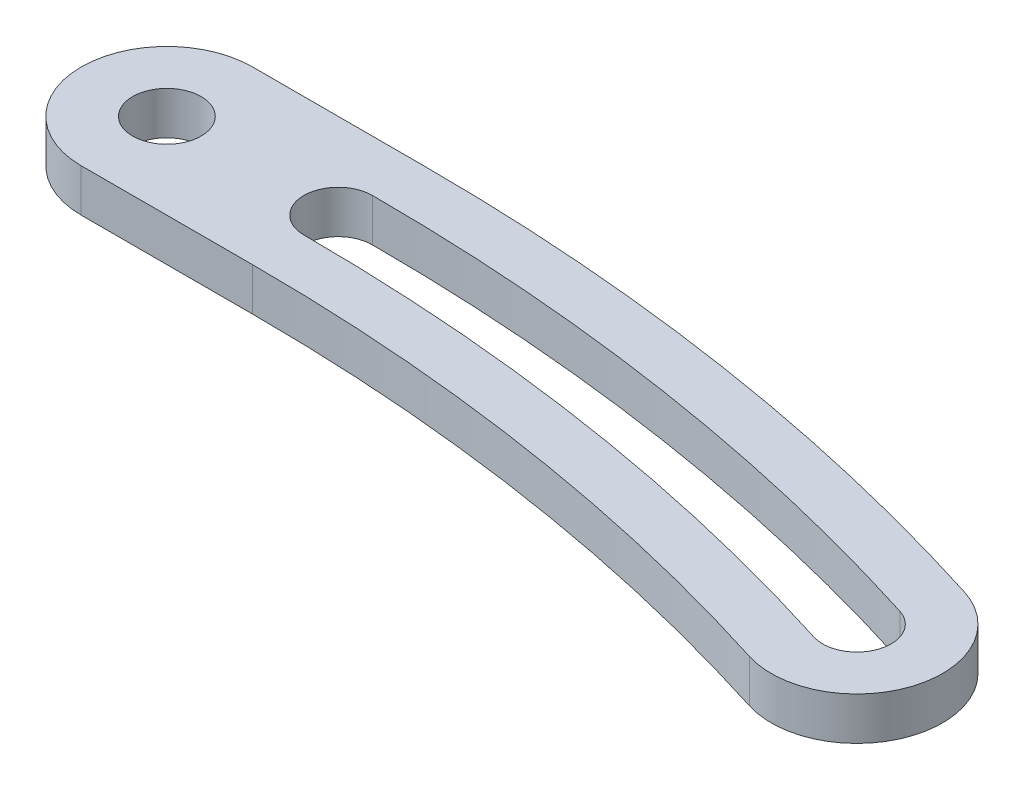
from build123d import *

# Parameters (mm, degrees)
SKETCH_2_R      = 1.6
EXTRUDE_1_DEPTH = 2


with BuildPart() as part:
    # 草图2 → 凸台-拉伸1 (new body)
    with BuildSketch(Plane(origin=(0, 0, 0), x_dir=(1, 0, 0), z_dir=(0, 1, 0))):
        with BuildLine():
            Line((-8, 4), (0, 4))
            ThreePointArc((0, 4), (15.110526316, 2.840032678), (29.866957344, -0.612686981))
            ThreePointArc((29.866957344, -0.612686981), (32.473840401, -5.633061541), (27.453465841, -8.239944598))
            ThreePointArc((27.453465841, -8.239944598), (13.889473684, -5.066232589), (0, -4))
            Line((0, -4), (-8, -4))
            ThreePointArc((-8, -4), (-12, 0), (-8, 4))
        make_face()
        with Locations((-8, 0)):
            Circle(SKETCH_2_R, mode=Mode.SUBTRACT)
        with BuildLine():
            ThreePointArc((29.142909893, -2.900864266), (14.744210526, 0.468153098), (0, 1.6))
            ThreePointArc((0, 1.6), (-1.6, 0), (0, -1.6))
            ThreePointArc((0, -1.6), (14.255789474, -2.694353009), (28.177513292, -5.951767313))
            ThreePointArc((28.177513292, -5.951767313), (30.185663116, -4.90901409), (29.142909893, -2.900864266))
        make_face(mode=Mode.SUBTRACT)
    extrude(amount=EXTRUDE_1_DEPTH)


solid = part.part
